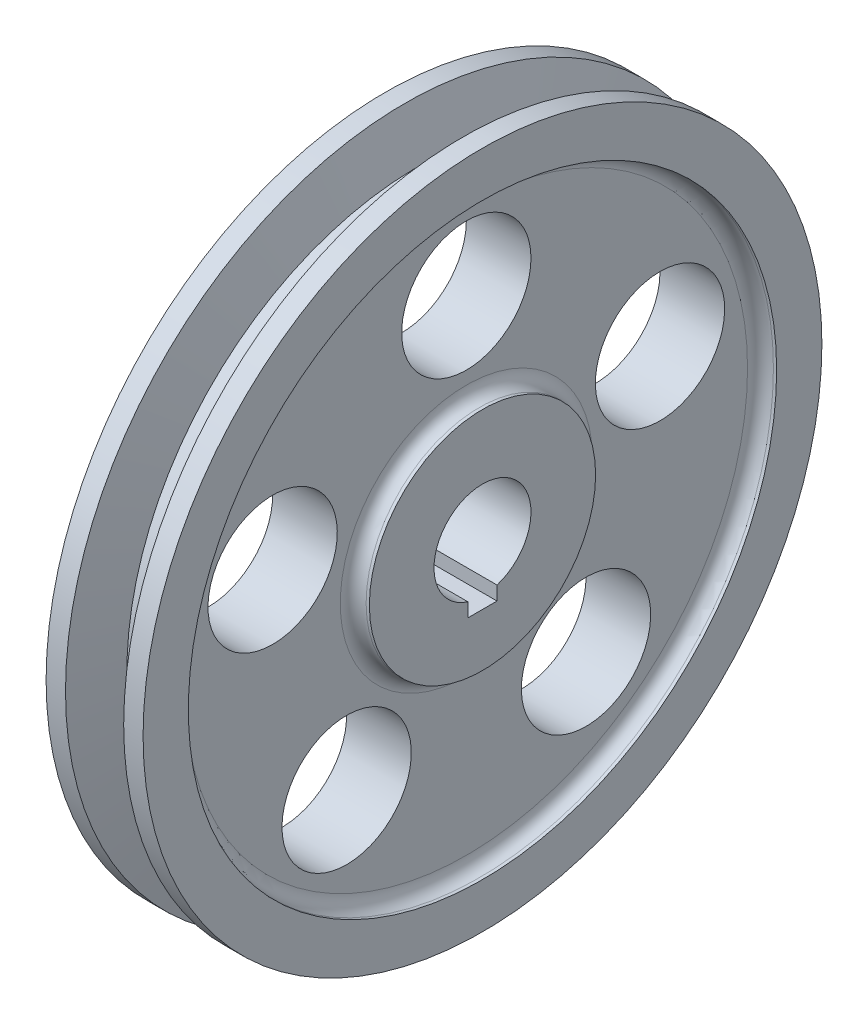
from build123d import *

# Parameters (mm, degrees)
SKETCH2_R         = 10
EXTRUDE1_DEPTH    = 10
CIRPATTERN1_COUNT = 5
SKETCH3_W         = 4.5
SKETCH3_H         = 2.3
EXTRUDE2_DEPTH    = 16


with BuildPart() as part:
    # Sketch1 → Revolve1 (revolve)
    with BuildSketch(Plane.XY):
        with BuildLine():
            Line((-7.5, 7.5), (7.5, 7.5))
            Line((7.5, 7.5), (7.5, 17.5))
            Line((7.5, 17.5), (7, 17.5))
            ThreePointArc((7, 17.5), (5.585786438, 18.085786438), (5, 19.5))
            Line((5, 19.5), (5, 43.5))
            ThreePointArc((5, 43.5), (5.585786438, 44.914213562), (7, 45.5))
            Line((7, 45.5), (7.5, 45.5))
            Line((7.5, 45.5), (7.5, 52.5))
            Line((7.5, 52.5), (4.5, 52.5))
            Line((4.5, 52.5), (2.5, 45))
            Line((2.5, 45), (-2.5, 45))
            Line((-2.5, 45), (-4.5, 52.5))
            Line((-4.5, 52.5), (-7.5, 52.5))
            Line((-7.5, 52.5), (-7.5, 45.5))
            Line((-7.5, 45.5), (-7, 45.5))
            ThreePointArc((-7, 45.5), (-5.585786438, 44.914213562), (-5, 43.5))
            Line((-5, 43.5), (-5, 19.5))
            ThreePointArc((-5, 19.5), (-5.585786438, 18.085786438), (-7, 17.5))
            Line((-7, 17.5), (-7.5, 17.5))
            Line((-7.5, 17.5), (-7.5, 7.5))
        make_face()
    revolve(axis=Axis((25.864037296, 0, 0), (-1, 0, 0)))

    # Sketch2 → Extrude1 (cut)
    with BuildSketch(Plane(origin=(5, 0, 0), x_dir=(0, 0, -1), z_dir=(1, 0, 0))):
        with Locations((0, 31.5)):
            Circle(SKETCH2_R)
    extrude1 = extrude(amount=-EXTRUDE1_DEPTH, mode=Mode.SUBTRACT)

    # CirPattern1: Extrude1 ×5 about axis
    cirpattern1_axis = Axis((0, 0, 0), (1, 0, 0))
    for i in range(1, CIRPATTERN1_COUNT):
        add(extrude1.rotate(cirpattern1_axis, i * 360 / CIRPATTERN1_COUNT), mode=Mode.SUBTRACT)

    # Sketch3 → Extrude2 (cut, through all)
    with BuildSketch(Plane(origin=(7.5, 0, 0), x_dir=(0, 0, -1), z_dir=(1, 0, 0))):
        with Locations((0, -8.15)):
            Rectangle(SKETCH3_W, SKETCH3_H)
    extrude(amount=-EXTRUDE2_DEPTH, mode=Mode.SUBTRACT)


solid = part.part
